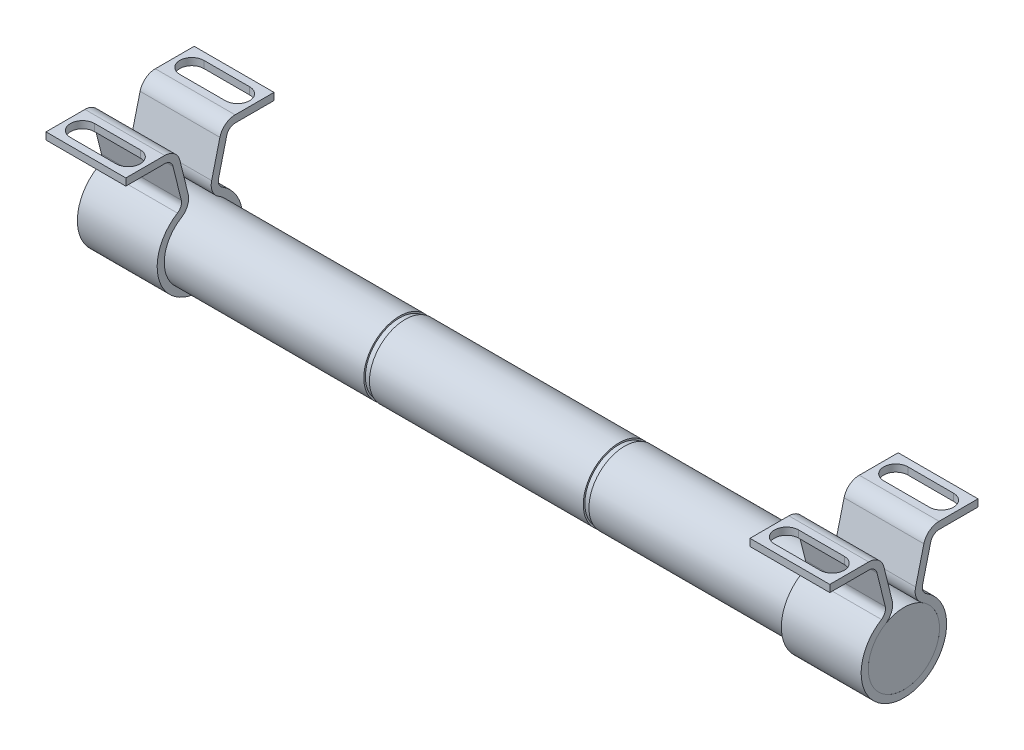
from build123d import *

# Parameters (mm, degrees)
SKETCH1_R                = 12.5
BOSS_EXTRUDE1_DEPTH      = 137.5
BOSS_EXTRUDE2_START      = -3
BOSS_EXTRUDE2_DEPTH      = 3
BOSS_EXTRUDE2_DEPTH_BACK = 25
CUT_EXTRUDE3_DEPTH       = 9
SKETCH6_R                = 13
SKETCH6_R_2              = 11.95
CUT_EXTRUDE2_DEPTH       = 2


with BuildPart() as part:
    # Sketch1 → Boss-Extrude1 (new body, symmetric)
    with BuildSketch(Plane(origin=(0, 0, 0), x_dir=(0, 0, -1), z_dir=(1, 0, 0))):
        Circle(SKETCH1_R)
    extrude(amount=BOSS_EXTRUDE1_DEPTH, both=True)

    # Sketch6 → Cut-Extrude2 (cut)
    with BuildSketch(Plane(origin=(37.5, 0, 0), x_dir=(0, 0, -1), z_dir=(1, 0, 0))):
        Circle(SKETCH6_R)
        Circle(SKETCH6_R_2, mode=Mode.SUBTRACT)
    cut_extrude2 = extrude(amount=CUT_EXTRUDE2_DEPTH, mode=Mode.SUBTRACT)

    # Mirror4: Cut-Extrude2 across plane
    add(cut_extrude2.mirror(Plane(origin=(0, 0, 0), x_dir=(0, 0, 1), z_dir=(1, 0, 0))), mode=Mode.SUBTRACT)


with BuildPart() as body_2:
    # Sketch2 → Boss-Extrude2 (new body, two sides)
    with BuildSketch(Plane(origin=(137.5, 0, 0), x_dir=(0, 0, -1), z_dir=(1, 0, 0)).offset(BOSS_EXTRUDE2_START)) as boss_extrude2_sk:
        with BuildLine():
            Line((-12.348050967, 32.5), (-26, 32.5))
            Line((-26, 32.5), (-26, 30))
            Line((-26, 30), (-12.348050967, 30))
            ThreePointArc((-12.348050967, 30), (-10.499016361, 29.362429052), (-9.435908919, 27.720714016))
            Line((-9.435908919, 27.720714016), (-6.544257006, 16.03660501))
            ThreePointArc((-6.544257006, 16.03660501), (-6.678858856, 14.182193305), (-7.880332545, 12.763242495))
            ThreePointArc((-7.880332545, 12.763242495), (0, -15), (7.880332545, 12.763242495))
            ThreePointArc((7.880332545, 12.763242495), (6.678858856, 14.182193305), (6.544257006, 16.03660501))
            Line((6.544257006, 16.03660501), (9.435908919, 27.720714016))
            ThreePointArc((9.435908919, 27.720714016), (10.499016361, 29.362429052), (12.348050967, 30))
            Line((12.348050967, 30), (26, 30))
            Line((26, 30), (26, 32.5))
            Line((26, 32.5), (12.348050967, 32.5))
            ThreePointArc((12.348050967, 32.5), (8.958154189, 31.331119928), (7.009123879, 28.321309029))
            Line((7.009123879, 28.321309029), (4.117471966, 16.637200023))
            ThreePointArc((4.117471966, 16.637200023), (4.364242024, 13.237445232), (6.566943787, 10.636035412))
            ThreePointArc((6.566943787, 10.636035412), (0, -12.5), (-6.566943787, 10.636035412))
            ThreePointArc((-6.566943787, 10.636035412), (-4.364242024, 13.237445232), (-4.117471966, 16.637200023))
            Line((-4.117471966, 16.637200023), (-7.009123879, 28.321309029))
            ThreePointArc((-7.009123879, 28.321309029), (-8.958154189, 31.331119928), (-12.348050967, 32.5))
        make_face()
    extrude(amount=BOSS_EXTRUDE2_DEPTH)
    extrude(boss_extrude2_sk.sketch, amount=-BOSS_EXTRUDE2_DEPTH_BACK)

    # Sketch8 → Cut-Extrude3 (cut)
    with BuildSketch(Plane(origin=(0, 32.5, 0), x_dir=(1, 0, 0), z_dir=(0, 1, 0))):
        with BuildLine():
            Line((115.5, 23.424025484), (131.5, 23.424025484))
            ThreePointArc((131.5, 23.424025484), (135.75, 19.174025484), (131.5, 14.924025484))
            Line((131.5, 14.924025484), (115.5, 14.924025484))
            ThreePointArc((115.5, 14.924025484), (111.25, 19.174025484), (115.5, 23.424025484))
        make_face()
    cut_extrude3 = extrude(amount=-CUT_EXTRUDE3_DEPTH, mode=Mode.SUBTRACT)

    # Mirror5: Cut-Extrude3 across plane
    add(cut_extrude3.mirror(Plane.XY), mode=Mode.SUBTRACT)


with BuildPart() as body_3:
    # Mirror1: mirrored copy
    add(body_2.part.mirror(Plane(origin=(0, 0, 0), x_dir=(0, 0, 1), z_dir=(1, 0, 0))))


solid = Compound([part.part, body_2.part, body_3.part])
